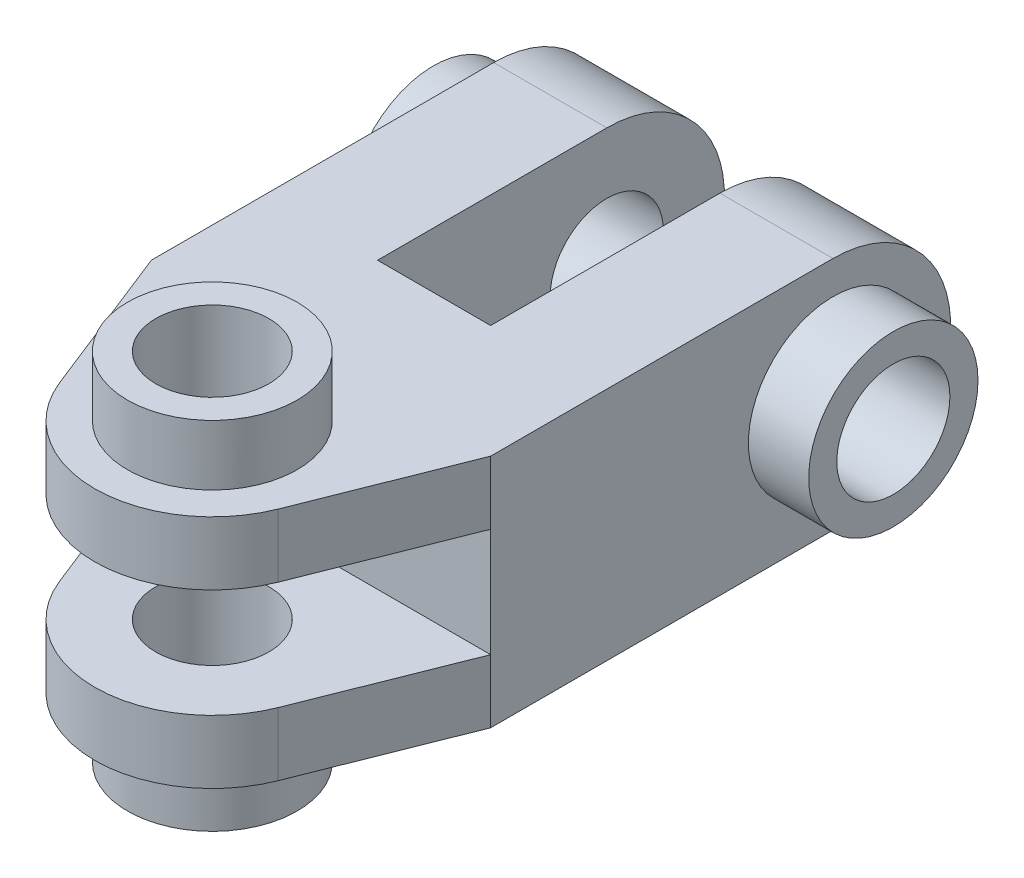
from build123d import *

# Parameters (mm, degrees)
SKETCH3_W           = 38.1
SKETCH3_H           = 10.668
BOSS_EXTRUDE1_DEPTH = 28.575
SKETCH4_W           = 19.05
SKETCH4_H           = 38.608
SKETCH4_H_2         = 19.812
SKETCH4_R           = 9.525
CUT_EXTRUDE1_DEPTH  = 40.624
SKETCH5_R           = 14.2875
SKETCH5_R_2         = 9.525
BOSS_EXTRUDE2_DEPTH = 10.16
BOSS_EXTRUDE3_START = -39.624
SKETCH5_3_R         = 14.2875
SKETCH5_3_R_2       = 9.525
BOSS_EXTRUDE3_DEPTH = 10.16
SKETCH6_R           = 9.525
CUT_EXTRUDE2_DEPTH  = 58.15
SKETCH7_R           = 14.25575
SKETCH7_R_2         = 9.525
BOSS_EXTRUDE4_DEPTH = 10.16
BOSS_EXTRUDE5_START = -57.15
SKETCH7_2_R         = 14.25575
SKETCH7_2_R_2       = 9.525
BOSS_EXTRUDE5_DEPTH = 10.16


with BuildPart() as part:
    # Sketch3 → Boss-Extrude1 (new body, symmetric)
    with BuildSketch(Plane(origin=(0, 0, 0), x_dir=(0, 0, -1), z_dir=(1, 0, 0))):
        with BuildLine():
            ThreePointArc((0, -19.812), (19.812, 0), (0, 19.812))
            Line((0, 19.812), (-57.658, 19.812))
            Line((-57.658, 19.812), (-57.658, 9.144))
            Line((-57.658, 9.144), (-57.658, -9.144))
            Line((-57.658, -9.144), (-57.658, -19.812))
            Line((-57.658, -19.812), (0, -19.812))
        make_face()
        with Locations((-76.708, 14.478)):
            Rectangle(SKETCH3_W, SKETCH3_H)
        with Locations((-76.708, -14.478)):
            Rectangle(SKETCH3_W, SKETCH3_H)
    extrude(amount=BOSS_EXTRUDE1_DEPTH, both=True)

    # Sketch4 → Cut-Extrude1 (cut, through all)
    with BuildSketch(Plane(origin=(0, 19.812, 0), x_dir=(1, 0, 0), z_dir=(0, 1, 0))):
        with Locations((0, -19.304)):
            Rectangle(SKETCH4_W, SKETCH4_H)
        with Locations((0, 9.906)):
            Rectangle(SKETCH4_W, SKETCH4_H_2)
        with BuildLine():
            Line((28.575, -95.758), (28.575, -57.658))
            Line((28.575, -57.658), (18.395099317, -83.264992565))
            ThreePointArc((18.395099317, -83.264992565), (11.109122589, -92.339889472), (-0.015432736, -95.758))
            Line((-0.015432736, -95.758), (28.575, -95.758))
        make_face()
        with Locations((-0.015432773, -75.946)):
            Circle(SKETCH4_R)
        with BuildLine():
            Line((-18.433578911, -83.24581074), (-28.575, -57.658))
            Line((-28.575, -57.658), (-28.575, -95.758))
            Line((-28.575, -95.758), (-0.015432736, -95.758))
            ThreePointArc((-0.015432736, -95.758), (-11.148525176, -92.334093164), (-18.433578911, -83.24581074))
        make_face()
    extrude(amount=-CUT_EXTRUDE1_DEPTH, mode=Mode.SUBTRACT)

    # Sketch5 → Boss-Extrude2 (add)
    with BuildSketch(Plane(origin=(0, 19.812, 0), x_dir=(1, 0, 0), z_dir=(0, 1, 0))):
        with Locations((-0.015432773, -75.946)):
            Circle(SKETCH5_R)
        with Locations((-0.015432773, -75.946)):
            Circle(SKETCH5_R_2, mode=Mode.SUBTRACT)
    extrude(amount=BOSS_EXTRUDE2_DEPTH)

    # Sketch5_3 → Boss-Extrude3 (add)
    with BuildSketch(Plane(origin=(0, 19.812, 0), x_dir=(1, 0, 0), z_dir=(0, 1, 0)).offset(BOSS_EXTRUDE3_START)):
        with Locations((-0.015432773, -75.946)):
            Circle(SKETCH5_3_R)
        with Locations((-0.015432773, -75.946)):
            Circle(SKETCH5_3_R_2, mode=Mode.SUBTRACT)
    extrude(amount=-BOSS_EXTRUDE3_DEPTH)

    # Sketch6 → Cut-Extrude2 (cut, through all)
    with BuildSketch(Plane(origin=(28.575, 0, 0), x_dir=(0, 0, -1), z_dir=(1, 0, 0))):
        Circle(SKETCH6_R)
    extrude(amount=-CUT_EXTRUDE2_DEPTH, mode=Mode.SUBTRACT)

    # Sketch7 → Boss-Extrude4 (add)
    with BuildSketch(Plane(origin=(28.575, 0, 0), x_dir=(0, 0, -1), z_dir=(1, 0, 0))):
        Circle(SKETCH7_R)
        Circle(SKETCH7_R_2, mode=Mode.SUBTRACT)
    extrude(amount=BOSS_EXTRUDE4_DEPTH)

    # Sketch7_2 → Boss-Extrude5 (add)
    with BuildSketch(Plane(origin=(28.575, 0, 0), x_dir=(0, 0, -1), z_dir=(1, 0, 0)).offset(BOSS_EXTRUDE5_START)):
        Circle(SKETCH7_2_R)
        Circle(SKETCH7_2_R_2, mode=Mode.SUBTRACT)
    extrude(amount=-BOSS_EXTRUDE5_DEPTH)


solid = part.part
